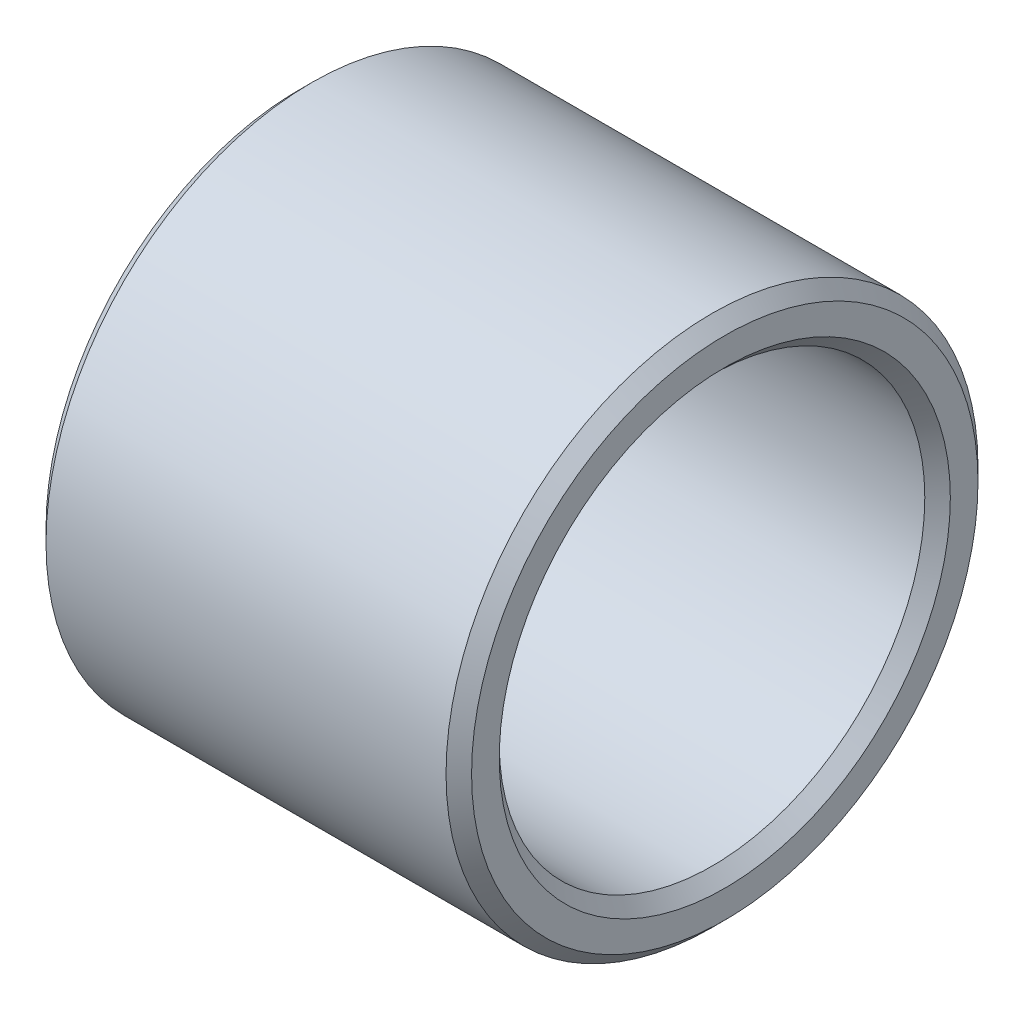
from build123d import *

# Parameters (mm, degrees)
SKETCH1_R           = 15.875
SKETCH1_R_2         = 12.7
BOSS_EXTRUDE1_DEPTH = 25.4
CHAMFER1_SIZE       = 0.762


with BuildPart() as part:
    # Sketch1 → Boss-Extrude1 (new body)
    with BuildSketch(Plane(origin=(0, 0, 0), x_dir=(0, 0, -1), z_dir=(1, 0, 0))):
        Circle(SKETCH1_R)
        Circle(SKETCH1_R_2, mode=Mode.SUBTRACT)
    extrude(amount=BOSS_EXTRUDE1_DEPTH)

    # Chamfer1
    chamfer1_edges = [part.edges().sort_by_distance(p)[0] for p in [
        (0, 0, 15.875),
        (25.4, 0, 15.875),
        (0, 0, 12.7),
        (25.4, 0, 12.7),
    ]]
    chamfer(chamfer1_edges, length=CHAMFER1_SIZE)


solid = part.part
